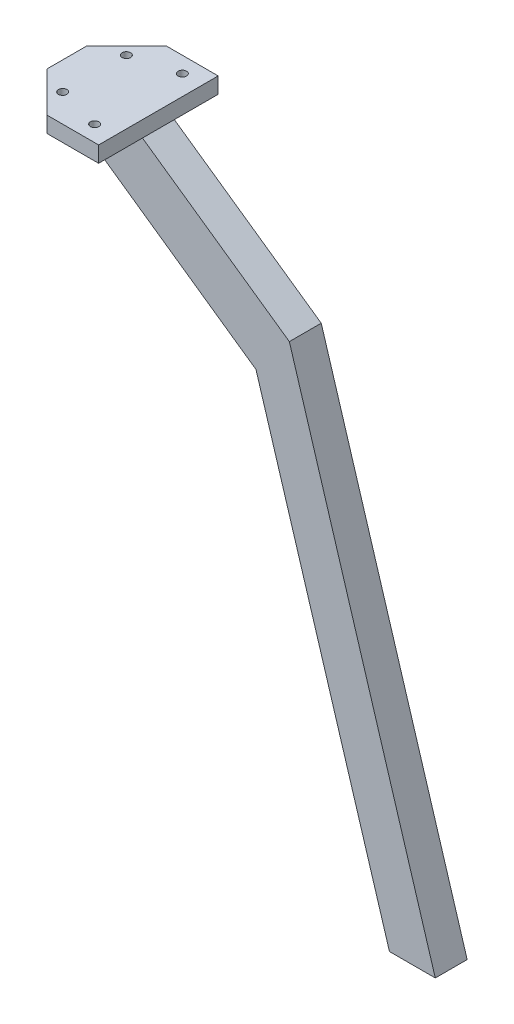
from build123d import *

# Parameters (mm, degrees)
SKETCH1_R                = 1.063985932
BOSS_EXTRUDE1_DEPTH      = 4
BOSS_EXTRUDE2_DEPTH      = 4
BOSS_EXTRUDE2_DEPTH_BACK = 4


with BuildPart() as part:
    # Sketch1 → Boss-Extrude1 (new body)
    with BuildSketch(Plane(origin=(0, 0, 0), x_dir=(1, 0, 0), z_dir=(0, 1, 0))):
        Polygon((0, 20), (10, 30), (23, 30), (23, 0), (10, 0), (0, 10), align=None)
        with Locations((6.969459898, 7)):
            Circle(SKETCH1_R, mode=Mode.SUBTRACT)
        with Locations((18, 4)):
            Circle(SKETCH1_R, mode=Mode.SUBTRACT)
        with Locations((18, 26)):
            Circle(SKETCH1_R, mode=Mode.SUBTRACT)
        with Locations((6.969459898, 23)):
            Circle(SKETCH1_R, mode=Mode.SUBTRACT)
    extrude(amount=BOSS_EXTRUDE1_DEPTH)

    # Sketch2 → Boss-Extrude2 (add, two sides)
    with BuildSketch(Plane.XY.offset(-15)) as boss_extrude2_sk:
        Polygon((0, 0), (51.486245577, -36.051057267), (84.98533082, -145.810939636), (96.486245577, -145.810939636), (59.861841993, -25.810939636), (23, 0), align=None)
    extrude(amount=BOSS_EXTRUDE2_DEPTH)
    extrude(boss_extrude2_sk.sketch, amount=-BOSS_EXTRUDE2_DEPTH_BACK)


solid = part.part
